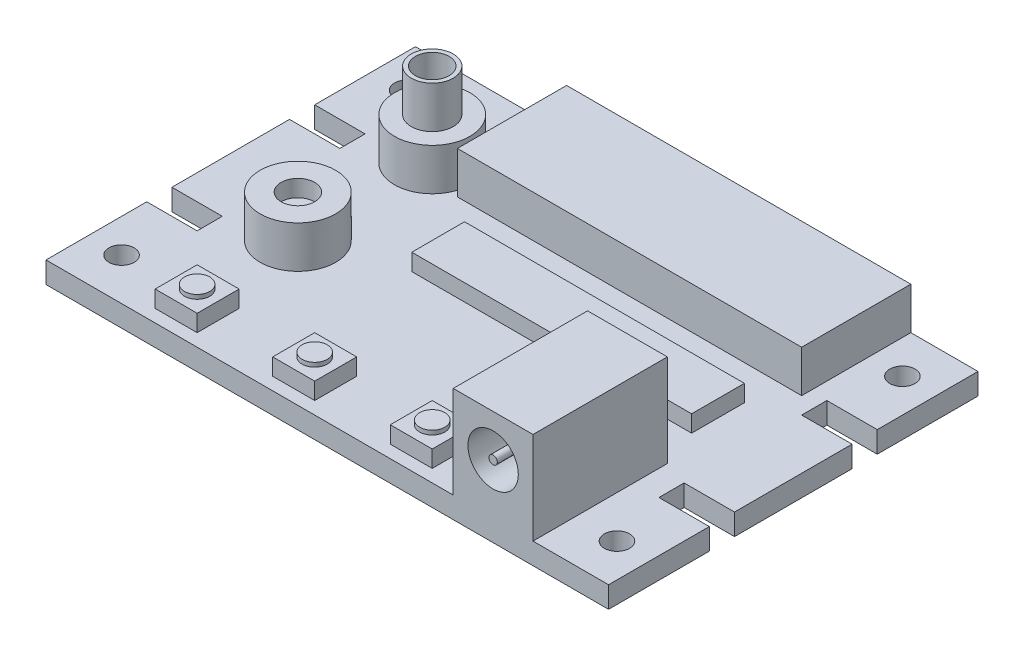
from build123d import *

# Parameters (mm, degrees)
BOSS_EXTRUDE1_DEPTH  = 2.54
SKETCH2_R            = 1.5
CUT_EXTRUDE1_DEPTH   = 3.54
SKETCH3_R            = 4.5
BOSS_EXTRUDE2_DEPTH  = 5
SKETCH4_R            = 2.5
SKETCH4_R_2          = 2
BOSS_EXTRUDE3_DEPTH  = 5
SKETCH5_R            = 2
CUT_EXTRUDE2_DEPTH   = 2
SKETCH6_W            = 41
SKETCH6_H            = 13
BOSS_EXTRUDE4_DEPTH  = 5
SKETCH7_W            = 5
SKETCH7_H            = 5
BOSS_EXTRUDE5_DEPTH  = 2
SKETCH8_R            = 1.5
BOSS_EXTRUDE6_DEPTH  = 0.5
SKETCH9_W            = 9.5
SKETCH9_H            = 16
BOSS_EXTRUDE7_DEPTH  = 11
SKETCH10_R           = 3
SKETCH10_R_2         = 0.5
CUT_EXTRUDE3_DEPTH   = 10
SKETCH11_W           = 33.328489161
SKETCH11_H           = 6.282155695
BOSS_EXTRUDE8_DEPTH  = 2
SKETCH12_W           = 8
SKETCH12_H           = 6
BOSS_EXTRUDE9_DEPTH  = 2
SKETCH13_R           = 0.5
BOSS_EXTRUDE10_DEPTH = 4


with BuildPart() as part:
    # Sketch1 → Boss-Extrude1 (new body)
    with BuildSketch(Plane(origin=(0, 0, 0), x_dir=(1, 0, 0), z_dir=(0, 1, 0))):
        Polygon((-33.5, 10), (-33.5, 22), (33.5, 22), (33.5, 10), (27.5, 10), (27.5, 7), (33.5, 7), (33.5, -7), (27.5, -7), (27.5, -10), (33.5, -10), (33.5, -22), (-33.5, -22), (-33.5, -10), (-27.5, -10), (-27.5, -7), (-33.5, -7), (-33.5, 7), (-27.5, 7), (-27.5, 10), align=None)
    extrude(amount=BOSS_EXTRUDE1_DEPTH)

    # Sketch2 → Cut-Extrude1 (cut, through all)
    with BuildSketch(Plane(origin=(0, 2.54, 0), x_dir=(1, 0, 0), z_dir=(0, 1, 0))):
        with Locations((-29.5, -17)):
            Circle(SKETCH2_R)
        with Locations((-29.5, 17)):
            Circle(SKETCH2_R)
        with Locations((29.5, 17)):
            Circle(SKETCH2_R)
        with Locations((29.5, -17)):
            Circle(SKETCH2_R)
    extrude(amount=-CUT_EXTRUDE1_DEPTH, mode=Mode.SUBTRACT)

    # Sketch3 → Boss-Extrude2 (add)
    with BuildSketch(Plane(origin=(0, 2.54, 0), x_dir=(1, 0, 0), z_dir=(0, 1, 0))):
        with Locations((-20.5, 11)):
            Circle(SKETCH3_R)
        with Locations((-20.5, -5)):
            Circle(SKETCH3_R)
    extrude(amount=BOSS_EXTRUDE2_DEPTH)

    # Sketch4 → Boss-Extrude3 (add)
    with BuildSketch(Plane(origin=(0, 7.54, 0), x_dir=(1, 0, 0), z_dir=(0, 1, 0))):
        with Locations((-20.5, 11)):
            Circle(SKETCH4_R)
        with Locations((-20.5, 11)):
            Circle(SKETCH4_R_2, mode=Mode.SUBTRACT)
    extrude(amount=BOSS_EXTRUDE3_DEPTH)

    # Sketch5 → Cut-Extrude2 (cut)
    with BuildSketch(Plane(origin=(0, 7.54, 0), x_dir=(1, 0, 0), z_dir=(0, 1, 0))):
        with Locations((-20.5, -5)):
            Circle(SKETCH5_R)
    extrude(amount=-CUT_EXTRUDE2_DEPTH, mode=Mode.SUBTRACT)

    # Sketch6 → Boss-Extrude4 (add)
    with BuildSketch(Plane(origin=(0, 2.54, 0), x_dir=(1, 0, 0), z_dir=(0, 1, 0))):
        with Locations((5, 15.5)):
            Rectangle(SKETCH6_W, SKETCH6_H)
    extrude(amount=BOSS_EXTRUDE4_DEPTH)

    # Sketch7 → Boss-Extrude5 (add)
    with BuildSketch(Plane(origin=(0, 2.54, 0), x_dir=(1, 0, 0), z_dir=(0, 1, 0))):
        with Locations((-19.5, -18)):
            Rectangle(SKETCH7_W, SKETCH7_H)
        with Locations((-5.5, -18)):
            Rectangle(SKETCH7_W, SKETCH7_H)
        with Locations((8.5, -18)):
            Rectangle(SKETCH7_W, SKETCH7_H)
    extrude(amount=BOSS_EXTRUDE5_DEPTH)

    # Sketch8 → Boss-Extrude6 (add)
    with BuildSketch(Plane(origin=(0, 4.54, 0), x_dir=(1, 0, 0), z_dir=(0, 1, 0))):
        with Locations((-19.5, -18)):
            Circle(SKETCH8_R)
        with Locations((-5.5, -18)):
            Circle(SKETCH8_R)
        with Locations((8.5, -18)):
            Circle(SKETCH8_R)
    extrude(amount=BOSS_EXTRUDE6_DEPTH)

    # Sketch9 → Boss-Extrude7 (add)
    with BuildSketch(Plane(origin=(0, 2.54, 0), x_dir=(1, 0, 0), z_dir=(0, 1, 0))):
        with Locations((19.75, -14)):
            Rectangle(SKETCH9_W, SKETCH9_H)
    extrude(amount=BOSS_EXTRUDE7_DEPTH)

    # Sketch10 → Cut-Extrude3 (cut)
    with BuildSketch(Plane.XY.offset(22)):
        with Locations((19.75, 8.54)):
            Circle(SKETCH10_R)
        with Locations((19.75, 8.54)):
            Circle(SKETCH10_R_2, mode=Mode.SUBTRACT)
    extrude(amount=-CUT_EXTRUDE3_DEPTH, mode=Mode.SUBTRACT)

    # Sketch11 → Boss-Extrude8 (add)
    with BuildSketch(Plane(origin=(0, 2.54, 0), x_dir=(1, 0, 0), z_dir=(0, 1, 0))):
        with Locations((6.149899785, 1.719326822)):
            Rectangle(SKETCH11_W, SKETCH11_H)
    extrude(amount=BOSS_EXTRUDE8_DEPTH)

    # Sketch12 → Boss-Extrude9 (add)
    with BuildSketch(Plane.XZ):
        with Locations((13.5, 1)):
            Rectangle(SKETCH12_W, SKETCH12_H)
    extrude(amount=BOSS_EXTRUDE9_DEPTH)

    # Sketch13 → Boss-Extrude10 (add)
    with BuildSketch(Plane.XZ.offset(2)):
        with Locations((10.5, 3)):
            Circle(SKETCH13_R)
        with Locations((13.5, 3)):
            Circle(SKETCH13_R)
        with Locations((16.5, 3)):
            Circle(SKETCH13_R)
        with Locations((16.5, -1)):
            Circle(SKETCH13_R)
        with Locations((13.5, -1)):
            Circle(SKETCH13_R)
        with Locations((10.5, -1)):
            Circle(SKETCH13_R)
    extrude(amount=BOSS_EXTRUDE10_DEPTH)


solid = part.part
